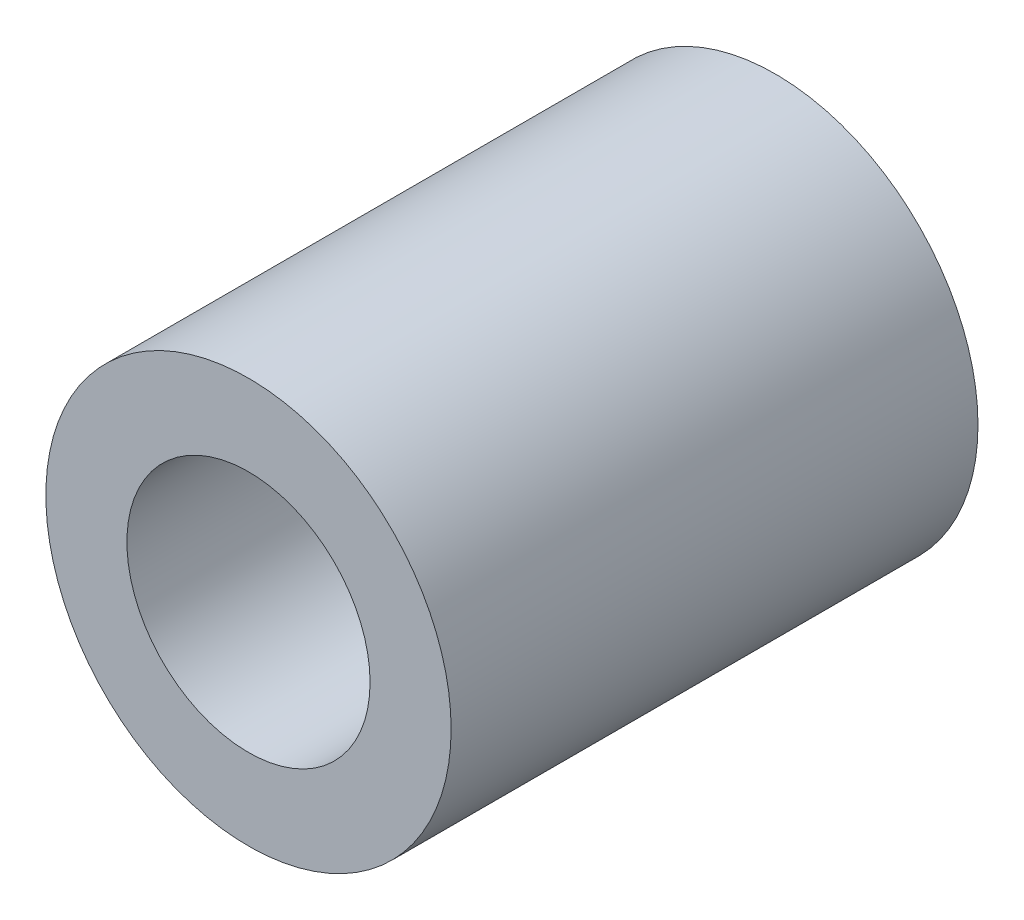
from build123d import *

# Parameters (mm, degrees)
ESQUISSE1_R        = 5
ESQUISSE1_R_2      = 3
BOSS_EXTRU_1_DEPTH = 13


with BuildPart() as part:
    # Esquisse1 → Boss.-Extru.1 (new body)
    with BuildSketch(Plane.XY):
        Circle(ESQUISSE1_R)
        Circle(ESQUISSE1_R_2, mode=Mode.SUBTRACT)
    extrude(amount=BOSS_EXTRU_1_DEPTH)


solid = part.part
